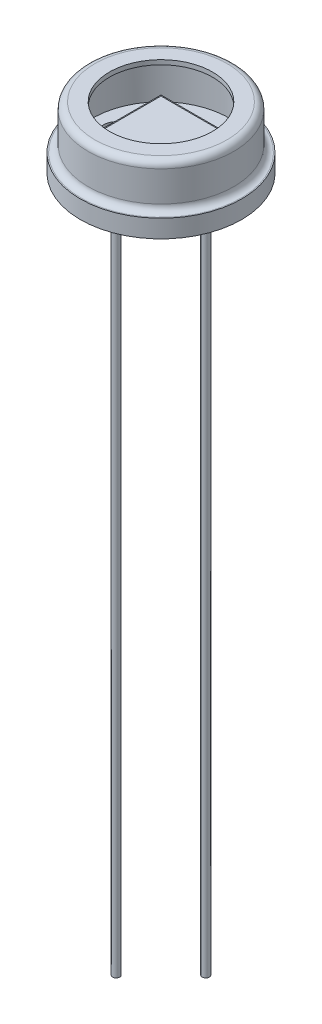
from build123d import *

# Parameters (mm, degrees)
SKETCH1_R                 = 4.1275
BODY_EXTRUDE_DEPTH        = 3.5052
FILLET1_R                 = 0.381
SHELL1_T                  = -0.254
SKETCH2_R                 = 4.572
FLANGE_EXTRUDE_DEPTH      = 1.016
FLANGE_FILLET_R           = 0.381
SKETCH4_R                 = 3.8735
FLANGE_DEPTH_CUTOUT_DEPTH = 0.254
WINDOW_CUTOUT_REACH       = 5.505
SKETCH3_R                 = 2.921
SKETCH6_R                 = 0.6985
PIN_RECESS_DEPTH          = 0.254
SKETCH10_W                = 3.81
SKETCH10_H                = 3.81
BOSS_EXTRUDE1_DEPTH       = 1.1684
SKETCH5_W                 = 3.5999928
SKETCH5_H                 = 3.5999928
DETECTOR_EXTRUDE_DEPTH    = 0.0508
TAB_EXTRUDE_DEPTH         = 0.762
TAB_FILLETS_R             = 0.127
SKETCH8_3_R               = 0.2032
EXTRUDE1_DEPTH            = 38.1
EXTRUDE1_DEPTH_BACK       = 0.762


with BuildPart() as part:
    # Sketch1 → Body Extrude (new body)
    with BuildSketch(Plane(origin=(0, 0, 0), x_dir=(1, 0, 0), z_dir=(0, 1, 0))):
        with Locations(Location((0, 0, 0), (0, 0, 270))):  # turned: the seam where the file's is
            Circle(SKETCH1_R)
    extrude(amount=BODY_EXTRUDE_DEPTH)

    # Fillet1
    fillet1_edges = [part.edges().sort_by_distance(p)[0] for p in [
        (0, 3.5052, -4.1275),
    ]]
    fillet(fillet1_edges, radius=FILLET1_R)

    # Shell1
    shell1_openings = [part.faces().sort_by_distance(p)[0] for p in [
        (0, 0, 0),
    ]]
    offset(amount=SHELL1_T, openings=shell1_openings, kind=Kind.INTERSECTION)

    # Sketch2 → Flange Extrude (add)
    with BuildSketch(Plane(origin=(0, 0, 0), x_dir=(1, 0, 0), z_dir=(0, 1, 0))):
        with Locations(Location((0, 0, 0), (0, 0, 270))):  # turned: the seam where the file's is
            Circle(SKETCH2_R)
    extrude(amount=FLANGE_EXTRUDE_DEPTH)

    # Flange Fillet
    flange_fillet_edges = [part.edges().sort_by_distance(p)[0] for p in [
        (0, 1.016, -4.1275),
    ]]
    fillet(flange_fillet_edges, radius=FLANGE_FILLET_R)

    # Sketch4 → Flange Depth Cutout (cut)
    with BuildSketch(Plane(origin=(0, 1.016, 0), x_dir=(-1, 0, 0), z_dir=(0, 1, 0))):
        with Locations(Location((0, 0, 0), (0, 0, 90))):  # turned: the seam where the file's is
            Circle(SKETCH4_R)
    extrude(amount=-FLANGE_DEPTH_CUTOUT_DEPTH, mode=Mode.SUBTRACT)

    # Sketch3 → Window Cutout (cut, up to next)
    with BuildSketch(Plane(origin=(0, 3.5052, 0), x_dir=(-1, 0, 0), z_dir=(0, 1, 0)), mode=Mode.PRIVATE) as window_cutout_sk1:
        with Locations(Location((0, 0, 0), (0, 0, 90))):  # turned: the seam where the file's is
            Circle(SKETCH3_R)
    window_cutout_tool1 = extrude(window_cutout_sk1.sketch, amount=-WINDOW_CUTOUT_REACH, mode=Mode.PRIVATE) & part.part
    add(window_cutout_tool1.solids().sort_by_distance((0, 3.5052, 0))[0], mode=Mode.SUBTRACT)

    # Sketch6 → Pin Recess (cut)
    with BuildSketch(Plane(origin=(0, 0.762, 0), x_dir=(-1, 0, 0), z_dir=(0, 1, 0))):
        with Locations(Location((-2.54, 0, 0), (0, 0, 90))):  # turned: the seam where the file's is
            Circle(SKETCH6_R)
        with Locations(Location((2.54, 0, 0), (0, 0, 90))):  # turned: the seam where the file's is
            Circle(SKETCH6_R)
    extrude(amount=-PIN_RECESS_DEPTH, mode=Mode.SUBTRACT)

    # Sketch10 → Boss-Extrude1 (add)
    with BuildSketch(Plane(origin=(0, 0.762, 0), x_dir=(1, 0, 0), z_dir=(0, 1, 0))):
        Rectangle(SKETCH10_W, SKETCH10_H)
    extrude(amount=BOSS_EXTRUDE1_DEPTH)

    # Sketch5 → Detector Extrude (add)
    with BuildSketch(Plane(origin=(0, 1.9304, 0), x_dir=(-1, 0, 0), z_dir=(0, 1, 0))):
        Rectangle(SKETCH5_W, SKETCH5_H)
    extrude(amount=DETECTOR_EXTRUDE_DEPTH)

    # Sketch7 → Tab Extrude (add)
    with BuildSketch(Plane(origin=(0, 0, 0), x_dir=(1, 0, 0), z_dir=(0, 1, 0))):
        with BuildLine():
            Line((-3.491055011, 2.952239643), (-4.220720377, 3.68190501))
            Line((-4.220720377, 3.68190501), (-3.68190501, 4.220720377))
            Line((-3.68190501, 4.220720377), (-2.952239643, 3.491055011))
            ThreePointArc((-2.952239643, 3.491055011), (-3.232892204, 3.232892204), (-3.491055011, 2.952239643))
        make_face()
    extrude(amount=TAB_EXTRUDE_DEPTH)

    # Tab Fillets
    tab_fillets_edges = [part.edges().sort_by_distance(p)[0] for p in [
        (-3.491055011, 0.381, -2.952239643),
        (-2.952239643, 0.381, -3.491055011),
        (-3.68190501, 0.381, -4.220720377),
        (-4.220720377, 0.381, -3.68190501),
    ]]
    fillet(tab_fillets_edges, radius=TAB_FILLETS_R)

    # Sketch8_3 → Extrude1 (add, two sides)
    with BuildSketch(Plane.XZ) as extrude1_sk:
        with Locations(Location((2.54, 0, 0), (0, 0, 90))):  # turned: the seam where the file's is
            Circle(SKETCH8_3_R)
        with Locations(Location((0, 2.54, 0), (0, 0, 270))):  # turned: the seam where the file's is
            Circle(SKETCH8_3_R)
        with Locations(Location((-2.54, 0, 0), (0, 0, 90))):  # turned: the seam where the file's is
            Circle(SKETCH8_3_R)
    extrude(amount=EXTRUDE1_DEPTH)
    extrude(extrude1_sk.sketch, amount=-EXTRUDE1_DEPTH_BACK)


solid = part.part
